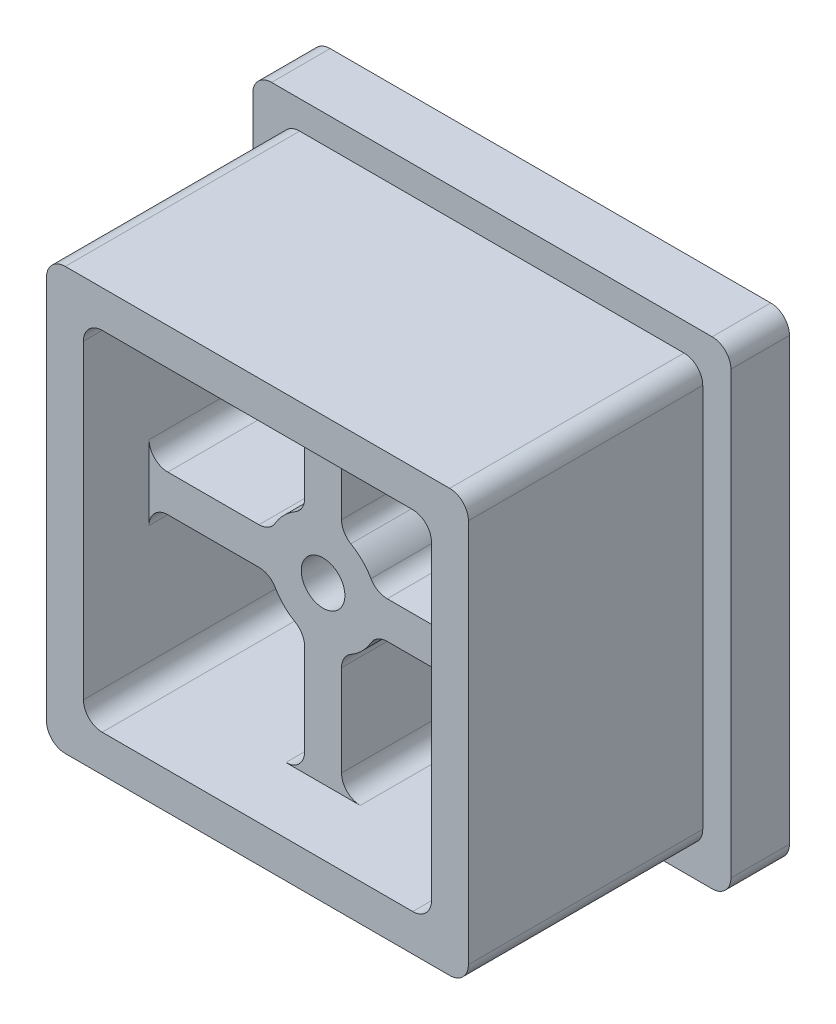
from build123d import *

# Parameters (mm, degrees)
SKETCH1_W                    = 11.43
SKETCH1_H                    = 11.43
BOSS_EXTRUDE1_DEPTH          = 4.7625
BOSS_EXTRUDE1_DEPTH_BACK     = 1.5875
SKETCH2_W                    = 12.954
SKETCH2_H                    = 12.954
BOSS_EXTRUDE2_DEPTH          = 1.5875
SHELL1_T                     = -1
SKETCH15_R                   = 1.499997
BOSS_EXTRUDE3_DEPTH          = 6.1595
SKETCH16_W                   = 1
SKETCH16_H                   = 9.43
SKETCH16_W_2                 = 9.43
SKETCH16_H_2                 = 1
EXTRUDE_THIN1_DEPTH          = 6.1595
BOSS_EXTRUDE4_REACH          = 9.938
SKETCH17_W                   = 10.954
SKETCH17_H                   = 10.954
SKETCH17_W_2                 = 9.43
SKETCH17_H_2                 = 9.43
FILLET7_R                    = 0.508
FILLET8_R                    = 0.508
F_56_0_0465_DIAMETER_HOLE1_D = 1.1811


with BuildPart() as part:
    # Sketch1 → Boss-Extrude1 (new body, two sides)
    with BuildSketch(Plane.XY) as boss_extrude1_sk:
        Rectangle(SKETCH1_W, SKETCH1_H)
    extrude(amount=BOSS_EXTRUDE1_DEPTH)
    extrude(boss_extrude1_sk.sketch, amount=-BOSS_EXTRUDE1_DEPTH_BACK)

    # Sketch2 → Boss-Extrude2 (add)
    with BuildSketch(Plane(origin=(0, 0, -1.5875), x_dir=(-1, 0, 0), z_dir=(0, 0, -1))):
        Rectangle(SKETCH2_W, SKETCH2_H)
    extrude(amount=BOSS_EXTRUDE2_DEPTH)

    # Shell1
    shell1_openings = [part.faces().sort_by_distance(p)[0] for p in [
        (0, 0, 4.7625),
        (0, 0, -3.175),
    ]]
    offset(amount=SHELL1_T, openings=shell1_openings, kind=Kind.INTERSECTION)



with BuildPart() as body_2:
    # Sketch15 → Boss-Extrude3 (new body)
    with BuildSketch(Plane(origin=(0, 0, -3.175), x_dir=(-1, 0, 0), z_dir=(0, 0, -1))):
        Circle(SKETCH15_R)
    extrude(amount=-BOSS_EXTRUDE3_DEPTH)


with BuildPart() as part_1:
    add(part.part)

    add(body_2.part)  # Extrude-Thin1 merges body 2
    # Sketch16 → Extrude-Thin1 (add)
    with BuildSketch(Plane.XY.offset(2.9845)):
        Rectangle(SKETCH16_W, SKETCH16_H)
        Rectangle(SKETCH16_W_2, SKETCH16_H_2)
    extrude(amount=-EXTRUDE_THIN1_DEPTH)

    # Sketch17 → Boss-Extrude4 (add, up to next)
    with BuildSketch(Plane(origin=(0, 0, -3.175), x_dir=(-1, 0, 0), z_dir=(0, 0, -1)), mode=Mode.PRIVATE) as boss_extrude4_sk1:
        Rectangle(SKETCH17_W, SKETCH17_H)
        Rectangle(SKETCH17_W_2, SKETCH17_H_2, mode=Mode.SUBTRACT)
    boss_extrude4_tool1 = extrude(boss_extrude4_sk1.sketch, amount=-BOSS_EXTRUDE4_REACH, mode=Mode.PRIVATE) - part_1.part
    add(boss_extrude4_tool1.solids().sort_by_distance((0, 5.322087, -3.175))[0])

    # Fillet7
    fillet7_edges = [part_1.edges().sort_by_distance(p)[0] for p in [
        (-6.477, 6.477, -2.38125),
        (6.477, 6.477, -2.38125),
        (6.477, -6.477, -2.38125),
        (-6.477, -6.477, -2.38125),
        (5.715, -5.715, 1.5875),
        (-5.715, -5.715, 1.5875),
        (-5.715, 5.715, 1.5875),
        (5.715, 5.715, 1.5875),
    ]]
    fillet(fillet7_edges, radius=FILLET7_R)

    # Fillet8
    fillet8_edges = [part_1.edges().sort_by_distance(p)[0] for p in [
        (4.715, 0.5, -0.09525),
        (-4.715, -0.5, -0.09525),
        (1.41421038, 0.5, -0.09525),
        (1.41421038, -0.5, -0.09525),
        (4.715, -0.5, -0.09525),
        (-4.715, 0.5, -0.09525),
        (4.715, 4.715, 0.79375),
        (4.715, -4.715, 0.79375),
        (-4.715, -4.715, 0.79375),
        (-4.715, 4.715, 0.79375),
        (-0.5, 4.715, -0.09525),
        (0.5, -4.715, -0.09525),
        (-0.5, -4.715, -0.09525),
        (0.5, 4.715, -0.09525),
        (0.5, 1.41421038, -0.09525),
        (0.5, -1.41421038, -0.09525),
        (-0.5, 1.41421038, -0.09525),
        (-0.5, -1.41421038, -0.09525),
        (-1.41421038, -0.5, -0.09525),
        (-1.41421038, 0.5, -0.09525),
    ]]
    fillet(fillet8_edges, radius=FILLET8_R)

    # #56 (0.0465) Diameter Hole1 (through all)
    with Locations(Plane.XY.offset(2.9845)):
        with Locations((0, 0)):
            Hole(F_56_0_0465_DIAMETER_HOLE1_D / 2)


solid = part_1.part
